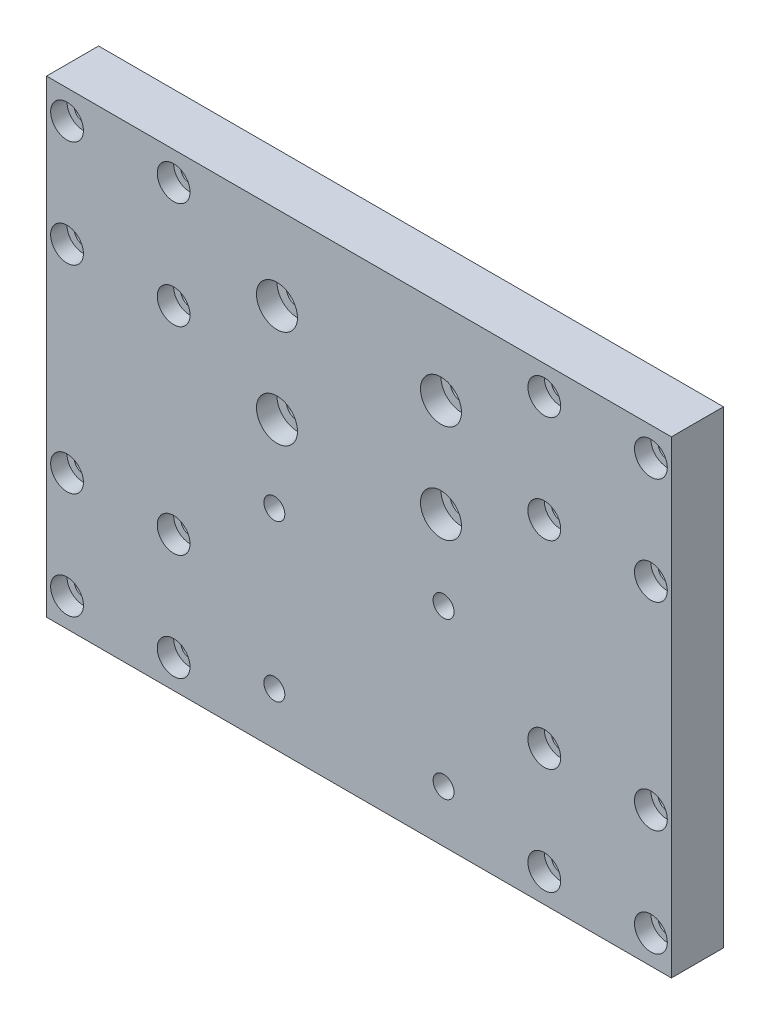
from build123d import *

# Parameters (mm, degrees)
SKETCH1_W                                       = 152.4
SKETCH1_H                                       = 114.3
BOSS_EXTRUDE1_DEPTH                             = 12.7
CBORE_FOR_10_SOCKET_HEAD_CAP_SCREW1_D           = 5.1054
CBORE_FOR_10_SOCKET_HEAD_CAP_SCREW1_CBORE_D     = 9.525
CBORE_FOR_10_SOCKET_HEAD_CAP_SCREW1_CBORE_DEPTH = 4.826
CBORE_FOR_M4_SHCS1_D                            = 4.5
CBORE_FOR_M4_SHCS1_CBORE_D                      = 8
CBORE_FOR_M4_SHCS1_CBORE_DEPTH                  = 4
MIRROR2_COPY_1_D                                = 4.5
MIRROR2_COPY_1_CBORE_D                          = 8
MIRROR2_COPY_1_CBORE_DEPTH                      = 4
CBORE_FOR_M5_SHCS1_D                            = 5.5
CBORE_FOR_M5_SHCS1_CBORE_D                      = 10
CBORE_FOR_M5_SHCS1_CBORE_DEPTH                  = 5


with BuildPart() as part:
    # Sketch1 → Boss-Extrude1 (new body)
    with BuildSketch(Plane.XY):
        Rectangle(SKETCH1_W, SKETCH1_H)
    extrude(amount=BOSS_EXTRUDE1_DEPTH)

    # CBORE for #10 Socket Head Cap Screw1 (through all)
    with Locations(Plane(origin=(0, 0, 0), x_dir=(-1, 0, 0), z_dir=(0, 0, -1))):
        with Locations((-20.6375, -6.35), (20.6375, -6.35), (20.6375, -44.45), (-20.6375, -44.45)):
            CounterBoreHole(CBORE_FOR_10_SOCKET_HEAD_CAP_SCREW1_D / 2, CBORE_FOR_10_SOCKET_HEAD_CAP_SCREW1_CBORE_D / 2, CBORE_FOR_10_SOCKET_HEAD_CAP_SCREW1_CBORE_DEPTH)

    # CBORE for M4 SHCS1 (through all)
    with Locations(Plane.XY.offset(12.7)):
        with Locations((-71.2, -50.15), (-45.2, -50.15), (-45.2, -24.15), (-71.2, -24.15)):
            cbore_for_m4_shcs1 = CounterBoreHole(CBORE_FOR_M4_SHCS1_D / 2, CBORE_FOR_M4_SHCS1_CBORE_D / 2, CBORE_FOR_M4_SHCS1_CBORE_DEPTH)

    # Mirror1: CBORE for M4 SHCS1 across plane
    add(cbore_for_m4_shcs1.mirror(Plane.ZX), mode=Mode.SUBTRACT)

    # Mirror2: CBORE for M4 SHCS1 across plane
    add(cbore_for_m4_shcs1.mirror(Plane(origin=(0, 0, 0), x_dir=(0, 0, 1), z_dir=(1, 0, 0))), mode=Mode.SUBTRACT)

    # Mirror2 copy 1 (through all)
    with Locations(Plane(origin=(0, 0, 12.7), x_dir=(-1, 0, 0), z_dir=(0, 0, 1))):
        with Locations((-71.2, -50.15), (-45.2, -50.15), (-45.2, -24.15), (-71.2, -24.15)):
            CounterBoreHole(MIRROR2_COPY_1_D / 2, MIRROR2_COPY_1_CBORE_D / 2, MIRROR2_COPY_1_CBORE_DEPTH)

    # CBORE for M5 SHCS1 (through all)
    with Locations(Plane.XY.offset(12.7)):
        with Locations((-20, 36.7), (20, 36.7), (20, 12.7), (-20, 12.7)):
            CounterBoreHole(CBORE_FOR_M5_SHCS1_D / 2, CBORE_FOR_M5_SHCS1_CBORE_D / 2, CBORE_FOR_M5_SHCS1_CBORE_DEPTH)


solid = part.part
